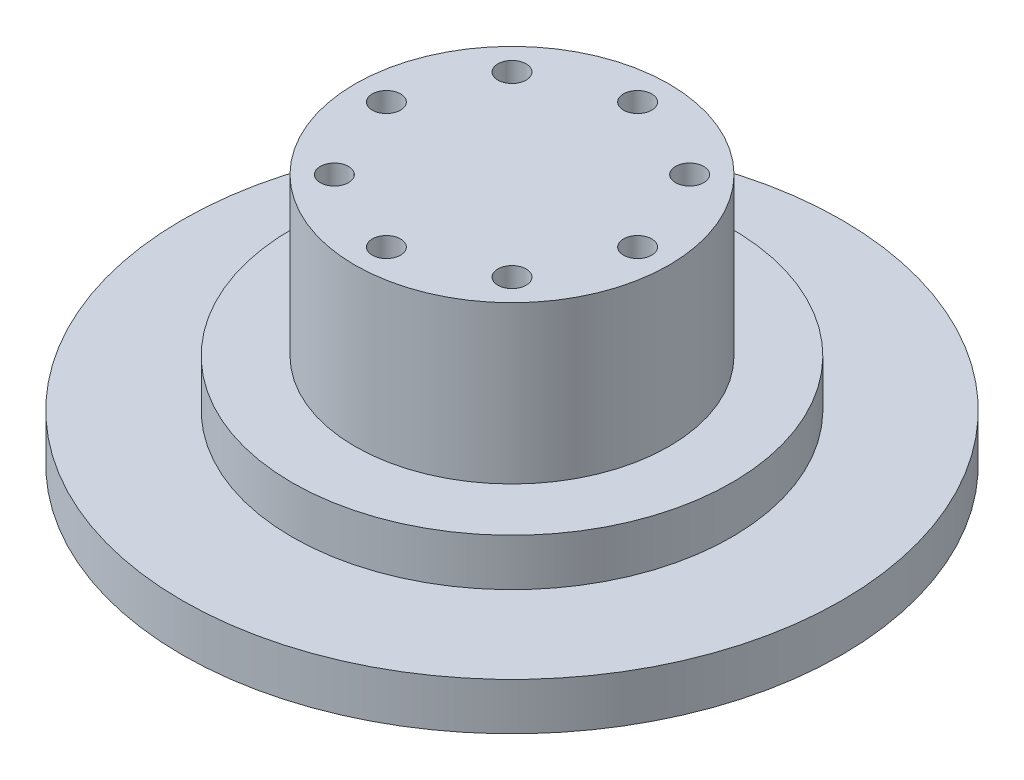
from build123d import *

# Parameters (mm, degrees)
SKETCH_1_R          = 21
EXTRUDE_1_DEPTH     = 3
SKETCH_2_R          = 10
EXTRUDE_2_DEPTH     = 13
SKETCH_3_R          = 14
EXTRUDE_3_DEPTH     = 3
SKETCH_4_R          = 0.9
CUT_EXTRUDE_1_DEPTH = 16


with BuildPart() as part:
    # 스케치1 → 보스-돌출1 (new body)
    with BuildSketch(Plane(origin=(0, 0, 0), x_dir=(1, 0, 0), z_dir=(0, 1, 0))):
        Circle(SKETCH_1_R)
    extrude(amount=EXTRUDE_1_DEPTH)

    # 스케치2 → 보스-돌출2 (add)
    with BuildSketch(Plane(origin=(0, 3, 0), x_dir=(1, 0, 0), z_dir=(0, 1, 0))):
        Circle(SKETCH_2_R)
    extrude(amount=EXTRUDE_2_DEPTH)

    # 스케치3 → 보스-돌출3 (add)
    with BuildSketch(Plane(origin=(0, 3, 0), x_dir=(1, 0, 0), z_dir=(0, 1, 0))):
        Circle(SKETCH_3_R)
    extrude(amount=EXTRUDE_3_DEPTH)

    # 스케치4 → 컷-돌출1 (cut)
    with BuildSketch(Plane.XZ):
        with Locations((8, 0)):
            Circle(SKETCH_4_R)
        with Locations((5.656854249, -5.656854249)):
            Circle(SKETCH_4_R)
        with Locations((5.656854249, 5.656854249)):
            Circle(SKETCH_4_R)
        with Locations((0, 8)):
            Circle(SKETCH_4_R)
        with Locations((-5.656854249, 5.656854249)):
            Circle(SKETCH_4_R)
        with Locations((0, -8)):
            Circle(SKETCH_4_R)
        with Locations((-5.656854249, -5.656854249)):
            Circle(SKETCH_4_R)
        with Locations((-8, 0)):
            Circle(SKETCH_4_R)
    extrude(amount=-CUT_EXTRUDE_1_DEPTH, mode=Mode.SUBTRACT)


solid = part.part
